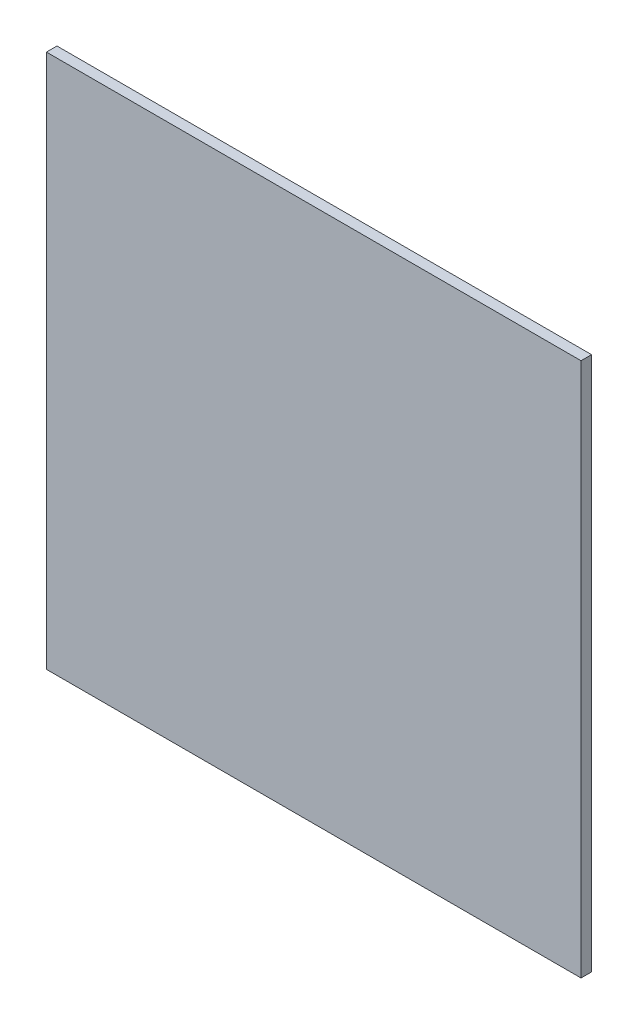
from build123d import *

# Parameters (mm, degrees)
SKETCH1_W           = 203.2
SKETCH1_H           = 203.2
BOSS_EXTRUDE1_DEPTH = 4


with BuildPart() as part:
    # Sketch1 → Boss-Extrude1 (new body)
    with BuildSketch(Plane.XY):
        Rectangle(SKETCH1_W, SKETCH1_H)
    extrude(amount=BOSS_EXTRUDE1_DEPTH)


solid = part.part
